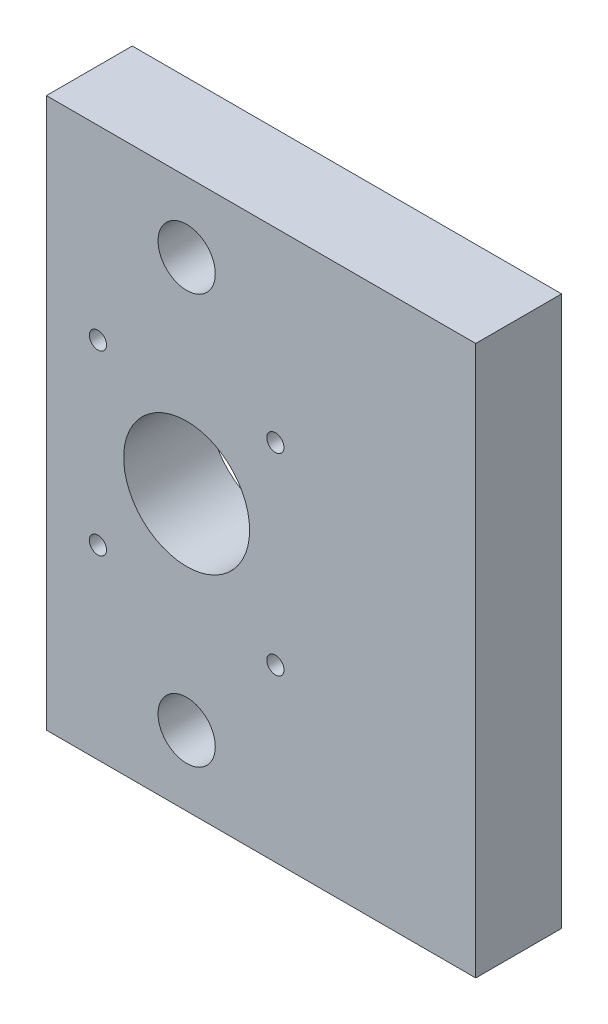
from build123d import *

# Parameters (mm, degrees)
SKETCH1_W           = 75
SKETCH1_H           = 96
SKETCH1_R           = 1.5
SKETCH1_R_2         = 11
SKETCH1_R_3         = 5
BOSS_EXTRUDE1_DEPTH = 15


with BuildPart() as part:
    # Sketch1 → Boss-Extrude1 (new body)
    with BuildSketch(Plane.XY):
        with Locations((-22.5, 268.509389187)):
            Rectangle(SKETCH1_W, SKETCH1_H)
        with Locations((-51, 253.009389187)):
            Circle(SKETCH1_R, mode=Mode.SUBTRACT)
        with Locations((-51, 284.009389187)):
            Circle(SKETCH1_R, mode=Mode.SUBTRACT)
        with Locations((-20, 250.370749596)):
            Circle(SKETCH1_R, mode=Mode.SUBTRACT)
        with Locations((-35.5, 268.509389187)):
            Circle(SKETCH1_R_2, mode=Mode.SUBTRACT)
        with Locations((-20, 284.009389187)):
            Circle(SKETCH1_R, mode=Mode.SUBTRACT)
        with Locations((-35.5, 232.728933645)):
            Circle(SKETCH1_R_3, mode=Mode.SUBTRACT)
        with Locations((-35.5, 304.28984473)):
            Circle(SKETCH1_R_3, mode=Mode.SUBTRACT)
    extrude(amount=BOSS_EXTRUDE1_DEPTH)


solid = part.part
